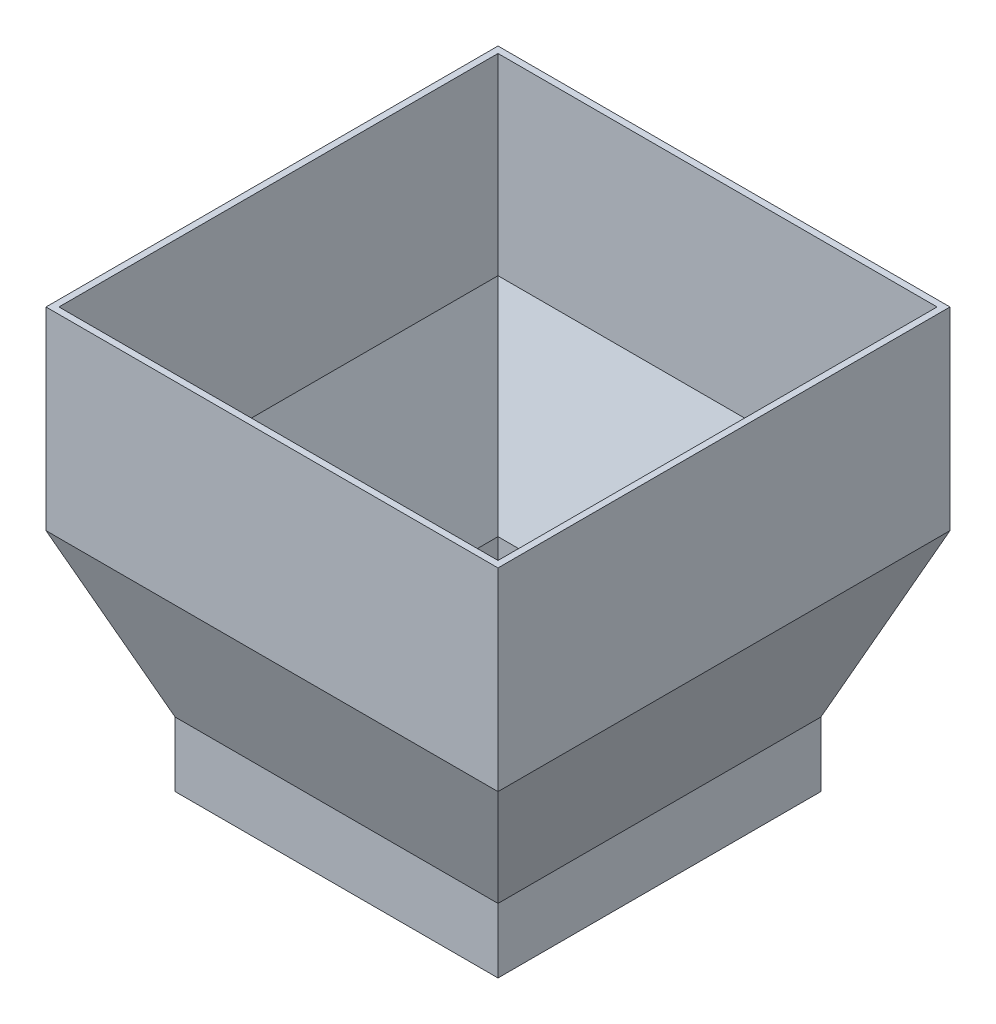
from build123d import *

# Parameters (mm, degrees)
SKETCH1_W           = 700
SKETCH1_H           = 700
BOSS_EXTRUDE1_DEPTH = 300
SKETCH2_W           = 500
SKETCH2_H           = 500
SKETCH3_W           = 500
SKETCH3_H           = 500
BOSS_EXTRUDE2_DEPTH = 100
SHELL1_T            = -10


with BuildPart() as part:
    # Sketch1 → Boss-Extrude1 (new body)
    with BuildSketch(Plane(origin=(0, 0, 0), x_dir=(1, 0, 0), z_dir=(0, 1, 0))):
        Rectangle(SKETCH1_W, SKETCH1_H)
    extrude(amount=BOSS_EXTRUDE1_DEPTH)

    # Sketch2 → section 1 of loft1
    with BuildSketch(Plane(origin=(0, -250, 0), x_dir=(-1, 0, 0), z_dir=(0, -1, 0)), mode=Mode.PRIVATE) as loft1_s1:
        Rectangle(SKETCH2_W, SKETCH2_H)
    # loft from a face of the part (loft1)
    loft([part.faces().sort_by_distance((0, 0, 0))[0], loft1_s1.sketch])

    # Sketch3 → Boss-Extrude2 (add)
    with BuildSketch(Plane.XZ.offset(250)):
        Rectangle(SKETCH3_W, SKETCH3_H)
    extrude(amount=BOSS_EXTRUDE2_DEPTH)

    # Shell1
    shell1_openings = [part.faces().sort_by_distance(p)[0] for p in [
        (0, 300, 0),
        (0, -350, 0),
    ]]
    offset(amount=SHELL1_T, openings=shell1_openings, kind=Kind.INTERSECTION)


solid = part.part
